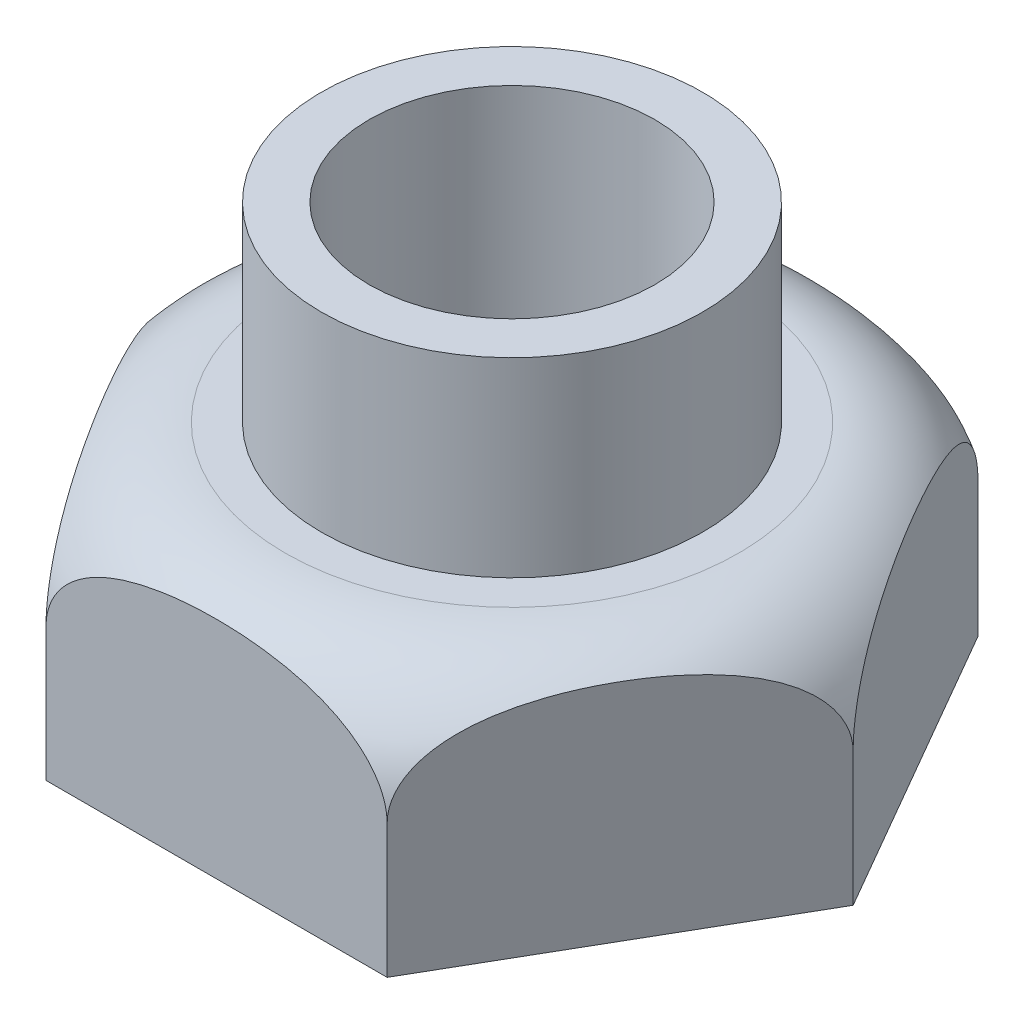
from build123d import *

# Parameters (mm, degrees)
BOSS_EXTRUDE1_DEPTH = 65
SKETCH4_R           = 50
SKETCH4_R_2         = 37.5
BOSS_EXTRUDE2_DEPTH = 50
SKETCH6_R           = 37.5
CUT_EXTRUDE1_DEPTH  = 81


with BuildPart() as part:
    # Sketch1 → Boss-Extrude1 (new body)
    with BuildSketch(Plane(origin=(0, 0, 0), x_dir=(1, 0, 0), z_dir=(0, 1, 0))):
        Polygon((-89.489291724, 0), (-44.744645862, -77.5), (44.744645862, -77.5), (89.489291724, 0), (44.744645862, 77.5), (-44.744645862, 77.5), align=None)
    extrude(amount=BOSS_EXTRUDE1_DEPTH)

    # Sketch4 → Boss-Extrude2 (add)
    with BuildSketch(Plane(origin=(0, 65, 0), x_dir=(1, 0, 0), z_dir=(0, 1, 0))):
        Circle(SKETCH4_R)
        Circle(SKETCH4_R_2, mode=Mode.SUBTRACT)
    extrude(amount=BOSS_EXTRUDE2_DEPTH)

    # Sketch6 → Cut-Extrude1 (cut)
    with BuildSketch(Plane(origin=(0, 65, 0), x_dir=(1, 0, 0), z_dir=(0, 1, 0))):
        Circle(SKETCH6_R)
    extrude(amount=-CUT_EXTRUDE1_DEPTH, mode=Mode.SUBTRACT)

    # Sketch7 → Cut-Revolve4 (revolve, cut)
    with BuildSketch(Plane.XY):
        with BuildLine():
            Line((59.489291724, 65), (89.489291724, 65))
            Line((89.489291724, 65), (89.489291724, 35))
            ThreePointArc((89.489291724, 35), (80.70249516, 56.213203436), (59.489291724, 65))
        make_face()
    revolve(axis=Axis((0, 115, 0), (0, -1, 0)), mode=Mode.SUBTRACT)


solid = part.part
